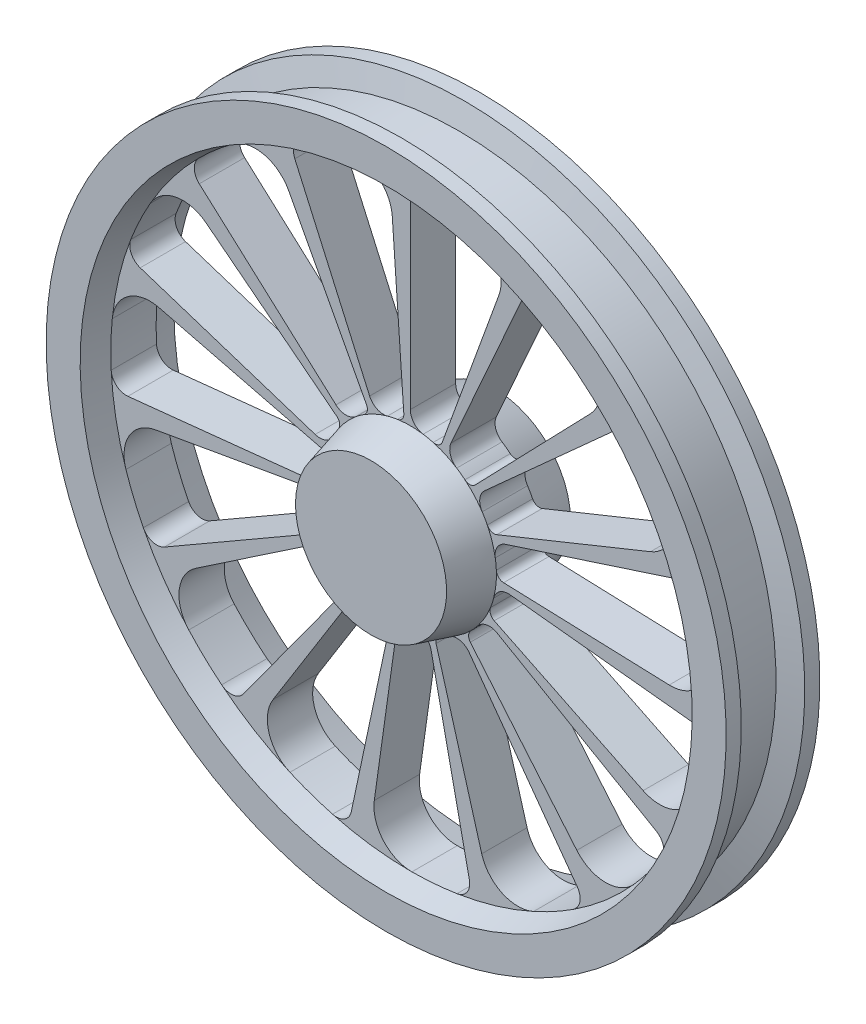
from build123d import *

# Parameters (mm, degrees)
WYTNIJ_WYCI_GNI_CIE1_DEPTH = 60
SZYK_KO_OWY1_COUNT         = 15


with BuildPart() as part:
    # Szkic1 → Obrót1 (revolve)
    with BuildSketch(Plane(origin=(0, 0, 0), x_dir=(0, 0, -1), z_dir=(1, 0, 0))):
        Polygon((0, 0), (0, 100), (52, 113.933358006), (52, 396.425625842), (20, 405), (20, 450), (40, 450), (48.038475773, 420), (115.961524227, 420), (124, 450), (144, 450), (144, 405), (112, 396.425625842), (112, 113.933358006), (164, 100), (164, 0), align=None)
    revolve(axis=Axis((0, 0, 0), (0, 0, -1)))

    # Szkic2 → Wytnij-wyciągnięcie1 (cut)
    with BuildSketch(Plane.XY.offset(-52)):
        with BuildLine():
            Line((0, 132.431659307), (0, 375.89393689))
            ThreePointArc((0, 375.89393689), (6.238687167, 390.406905887), (21.062626911, 395.865687541))
            ThreePointArc((21.062626911, 395.865687541), (50.876346681, 393.147394971), (80.399918044, 388.186978147))
            ThreePointArc((80.399918044, 388.186978147), (113.926995228, 363.580426532), (117.243943531, 322.12508742))
            Line((117.243943531, 322.12508742), (42.249494034, 116.079530842))
            ThreePointArc((42.249494034, 116.079530842), (37.441245649, 110.614686646), (30.201742548, 109.857475001))
            ThreePointArc((30.201742548, 109.857475001), (23.649020488, 111.451935365), (17.013440072, 112.655904965))
            ThreePointArc((17.013440072, 112.655904965), (4.83868082, 119.388101483), (0, 132.431659307))
        make_face()
    wytnij_wyci_gni_cie1 = extrude(amount=-WYTNIJ_WYCI_GNI_CIE1_DEPTH, mode=Mode.SUBTRACT)

    # Szyk kołowy1: Wytnij-wyciągnięcie1 ×15 about axis
    szyk_ko_owy1_axis = Axis((0, 0, 0), (0, 0, 1))
    for i in range(1, SZYK_KO_OWY1_COUNT):
        add(wytnij_wyci_gni_cie1.rotate(szyk_ko_owy1_axis, i * 360 / SZYK_KO_OWY1_COUNT), mode=Mode.SUBTRACT)


solid = part.part
